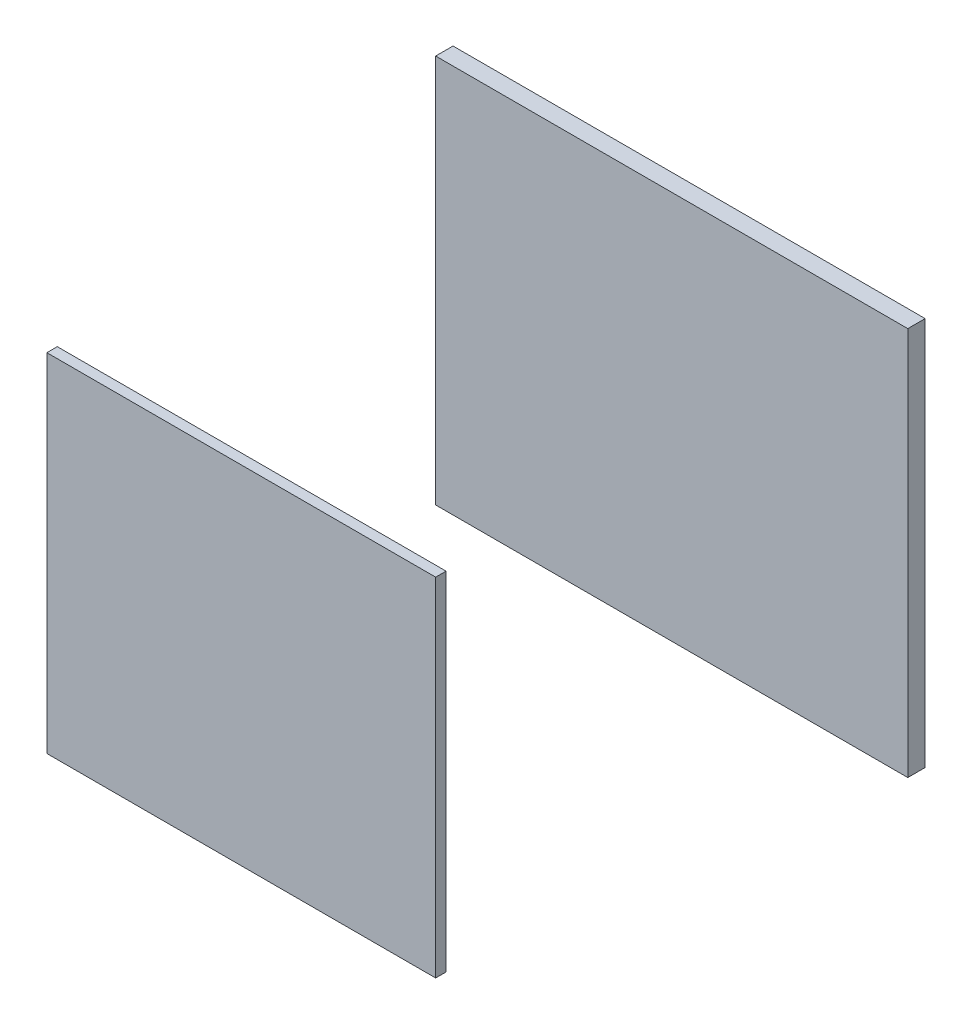
from build123d import *

# Parameters (mm, degrees)
SKETCH_6_W             = 560
SKETCH_6_H             = 500
EXTRUDE_312_DEPTH      = 15
SKETCH_7_W             = 680
SKETCH_7_H             = 560
EXTRUDE_428_DEPTH      = 5
EXTRUDE_428_DEPTH_BACK = 20


with BuildPart() as part:
    # Эскиз6 → Extrude 312 (new body)
    with BuildSketch(Plane.XY):
        Rectangle(SKETCH_6_W, SKETCH_6_H)
    extrude(amount=-EXTRUDE_312_DEPTH)


with BuildPart() as body_2:
    # Эскиз7 → Extrude 428 (new body, two sides)
    with BuildSketch(Plane.XY.offset(-625)) as extrude_428_sk:
        Rectangle(SKETCH_7_W, SKETCH_7_H)
    extrude(amount=EXTRUDE_428_DEPTH)
    extrude(extrude_428_sk.sketch, amount=-EXTRUDE_428_DEPTH_BACK)


solid = Compound([part.part, body_2.part])
